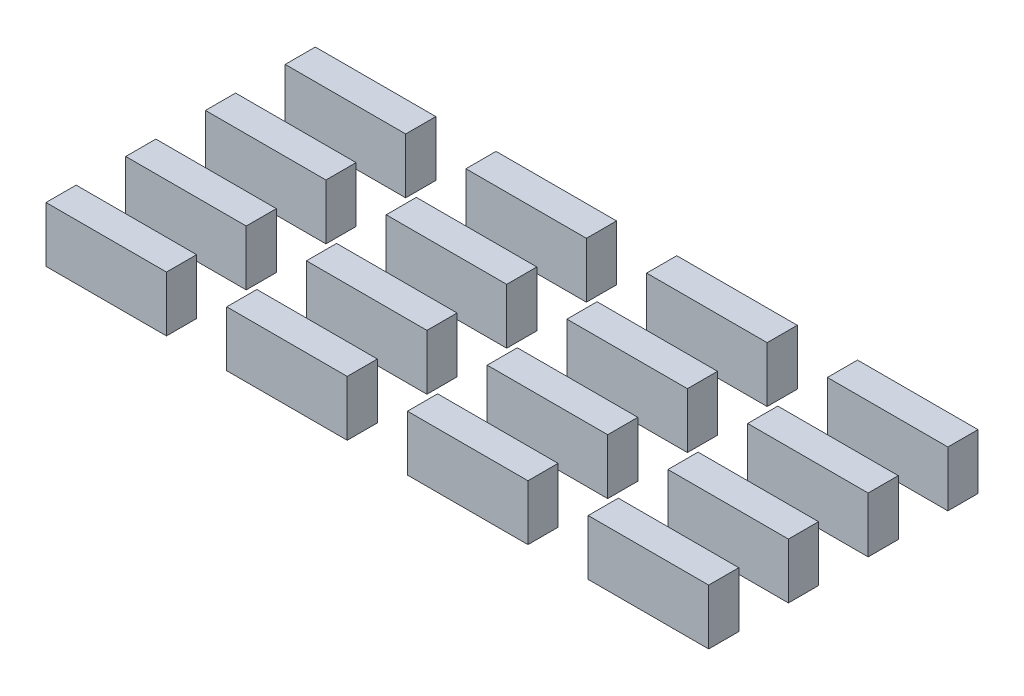
from build123d import *

# Parameters (mm, degrees)
SKETCH1_W              = 16
SKETCH1_H              = 4
BOSS_EXTRUDE1_DEPTH    = 7.35
BOSS_EXTRUDE1_2_DEPTH  = 7.35
BOSS_EXTRUDE1_3_DEPTH  = 7.35
BOSS_EXTRUDE1_4_DEPTH  = 7.35
BOSS_EXTRUDE1_5_DEPTH  = 7.35
BOSS_EXTRUDE1_6_DEPTH  = 7.35
BOSS_EXTRUDE1_7_DEPTH  = 7.35
BOSS_EXTRUDE1_8_DEPTH  = 7.35
BOSS_EXTRUDE1_9_DEPTH  = 7.35
BOSS_EXTRUDE1_10_DEPTH = 7.35
BOSS_EXTRUDE1_11_DEPTH = 7.35
BOSS_EXTRUDE1_12_DEPTH = 7.35
BOSS_EXTRUDE1_13_DEPTH = 7.35
BOSS_EXTRUDE1_14_DEPTH = 7.35
BOSS_EXTRUDE1_15_DEPTH = 7.35
BOSS_EXTRUDE1_16_DEPTH = 7.35


with BuildPart() as part:
    # Sketch1 → Boss-Extrude1 (new body)
    with BuildSketch(Plane(origin=(0, 0, 0), x_dir=(1, 0, 0), z_dir=(0, 1, 0))):
        with Locations((39, 10.5)):
            Rectangle(SKETCH1_W, SKETCH1_H)
    extrude(amount=-BOSS_EXTRUDE1_DEPTH)


with BuildPart() as body_2:
    # Sketch1 → Boss-Extrude1 2 (new body)
    with BuildSketch(Plane(origin=(0, 0, 0), x_dir=(1, 0, 0), z_dir=(0, 1, 0))):
        with Locations((15, 10.5)):
            Rectangle(SKETCH1_W, SKETCH1_H)
    extrude(amount=-BOSS_EXTRUDE1_2_DEPTH)


with BuildPart() as body_3:
    # Sketch1 → Boss-Extrude1 3 (new body)
    with BuildSketch(Plane(origin=(0, 0, 0), x_dir=(1, 0, 0), z_dir=(0, 1, 0))):
        with Locations((63, 10.5)):
            Rectangle(SKETCH1_W, SKETCH1_H)
    extrude(amount=-BOSS_EXTRUDE1_3_DEPTH)


with BuildPart() as body_4:
    # Sketch1 → Boss-Extrude1 4 (new body)
    with BuildSketch(Plane(origin=(0, 0, 0), x_dir=(1, 0, 0), z_dir=(0, 1, 0))):
        with Locations((87, 10.5)):
            Rectangle(SKETCH1_W, SKETCH1_H)
    extrude(amount=-BOSS_EXTRUDE1_4_DEPTH)


with BuildPart() as body_5:
    # Sketch1 → Boss-Extrude1 5 (new body)
    with BuildSketch(Plane(origin=(0, 0, 0), x_dir=(1, 0, 0), z_dir=(0, 1, 0))):
        with Locations((15, 21.0875)):
            Rectangle(SKETCH1_W, SKETCH1_H)
    extrude(amount=-BOSS_EXTRUDE1_5_DEPTH)


with BuildPart() as body_6:
    # Sketch1 → Boss-Extrude1 6 (new body)
    with BuildSketch(Plane(origin=(0, 0, 0), x_dir=(1, 0, 0), z_dir=(0, 1, 0))):
        with Locations((39, 21.0875)):
            Rectangle(SKETCH1_W, SKETCH1_H)
    extrude(amount=-BOSS_EXTRUDE1_6_DEPTH)


with BuildPart() as body_7:
    # Sketch1 → Boss-Extrude1 7 (new body)
    with BuildSketch(Plane(origin=(0, 0, 0), x_dir=(1, 0, 0), z_dir=(0, 1, 0))):
        with Locations((63, 21.0875)):
            Rectangle(SKETCH1_W, SKETCH1_H)
    extrude(amount=-BOSS_EXTRUDE1_7_DEPTH)


with BuildPart() as body_8:
    # Sketch1 → Boss-Extrude1 8 (new body)
    with BuildSketch(Plane(origin=(0, 0, 0), x_dir=(1, 0, 0), z_dir=(0, 1, 0))):
        with Locations((87, 21.0875)):
            Rectangle(SKETCH1_W, SKETCH1_H)
    extrude(amount=-BOSS_EXTRUDE1_8_DEPTH)


with BuildPart() as body_9:
    # Sketch1 → Boss-Extrude1 9 (new body)
    with BuildSketch(Plane(origin=(0, 0, 0), x_dir=(1, 0, 0), z_dir=(0, 1, 0))):
        with Locations((15, 31.675)):
            Rectangle(SKETCH1_W, SKETCH1_H)
    extrude(amount=-BOSS_EXTRUDE1_9_DEPTH)


with BuildPart() as body_10:
    # Sketch1 → Boss-Extrude1 10 (new body)
    with BuildSketch(Plane(origin=(0, 0, 0), x_dir=(1, 0, 0), z_dir=(0, 1, 0))):
        with Locations((39, 31.675)):
            Rectangle(SKETCH1_W, SKETCH1_H)
    extrude(amount=-BOSS_EXTRUDE1_10_DEPTH)


with BuildPart() as body_11:
    # Sketch1 → Boss-Extrude1 11 (new body)
    with BuildSketch(Plane(origin=(0, 0, 0), x_dir=(1, 0, 0), z_dir=(0, 1, 0))):
        with Locations((63, 31.675)):
            Rectangle(SKETCH1_W, SKETCH1_H)
    extrude(amount=-BOSS_EXTRUDE1_11_DEPTH)


with BuildPart() as body_12:
    # Sketch1 → Boss-Extrude1 12 (new body)
    with BuildSketch(Plane(origin=(0, 0, 0), x_dir=(1, 0, 0), z_dir=(0, 1, 0))):
        with Locations((87, 31.675)):
            Rectangle(SKETCH1_W, SKETCH1_H)
    extrude(amount=-BOSS_EXTRUDE1_12_DEPTH)


with BuildPart() as body_13:
    # Sketch1 → Boss-Extrude1 13 (new body)
    with BuildSketch(Plane(origin=(0, 0, 0), x_dir=(1, 0, 0), z_dir=(0, 1, 0))):
        with Locations((15, 42.2625)):
            Rectangle(SKETCH1_W, SKETCH1_H)
    extrude(amount=-BOSS_EXTRUDE1_13_DEPTH)


with BuildPart() as body_14:
    # Sketch1 → Boss-Extrude1 14 (new body)
    with BuildSketch(Plane(origin=(0, 0, 0), x_dir=(1, 0, 0), z_dir=(0, 1, 0))):
        with Locations((39, 42.2625)):
            Rectangle(SKETCH1_W, SKETCH1_H)
    extrude(amount=-BOSS_EXTRUDE1_14_DEPTH)


with BuildPart() as body_15:
    # Sketch1 → Boss-Extrude1 15 (new body)
    with BuildSketch(Plane(origin=(0, 0, 0), x_dir=(1, 0, 0), z_dir=(0, 1, 0))):
        with Locations((63, 42.2625)):
            Rectangle(SKETCH1_W, SKETCH1_H)
    extrude(amount=-BOSS_EXTRUDE1_15_DEPTH)


with BuildPart() as body_16:
    # Sketch1 → Boss-Extrude1 16 (new body)
    with BuildSketch(Plane(origin=(0, 0, 0), x_dir=(1, 0, 0), z_dir=(0, 1, 0))):
        with Locations((87, 42.2625)):
            Rectangle(SKETCH1_W, SKETCH1_H)
    extrude(amount=-BOSS_EXTRUDE1_16_DEPTH)


solid = Compound([part.part, body_2.part, body_3.part, body_4.part, body_5.part, body_6.part, body_7.part, body_8.part, body_9.part, body_10.part, body_11.part, body_12.part, body_13.part, body_14.part, body_15.part, body_16.part])
